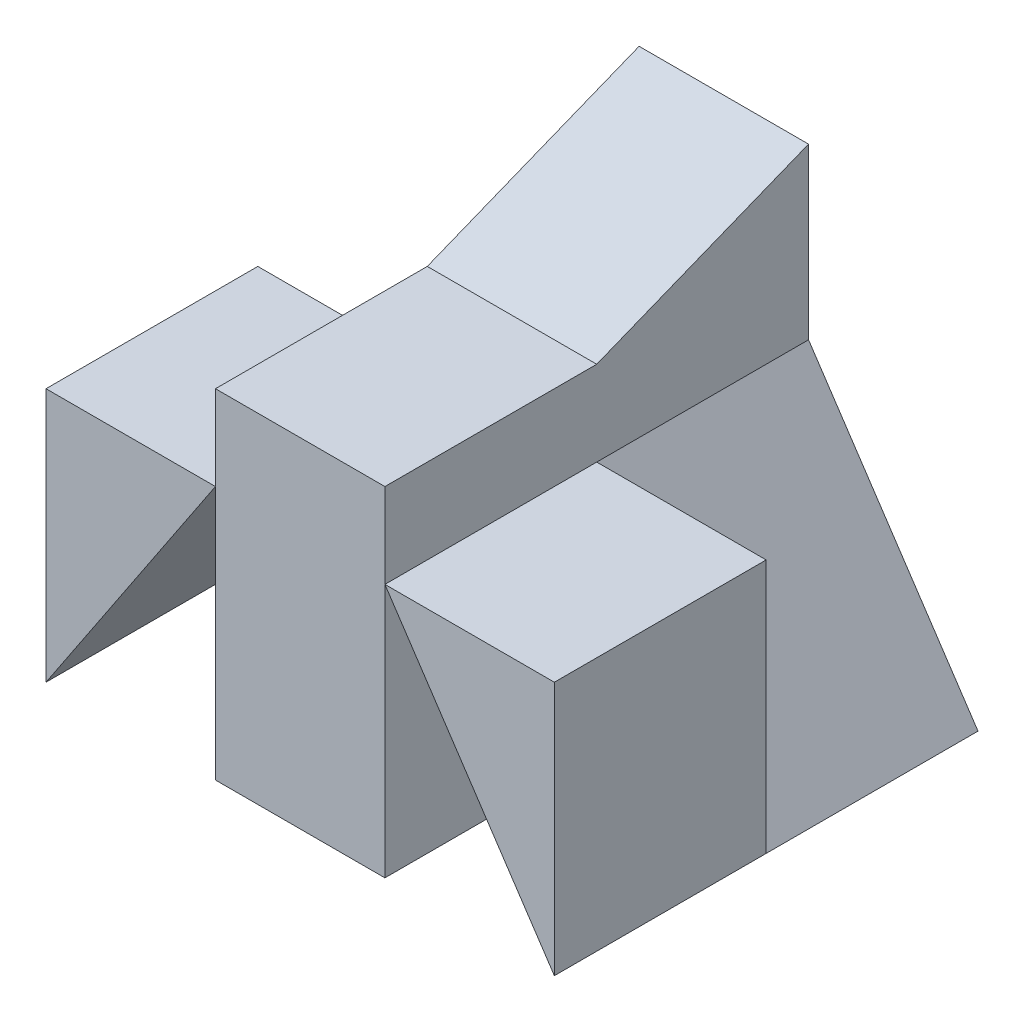
from build123d import *

# Parameters (mm, degrees)
SKETCH1_W           = 6
SKETCH1_H           = 3
SKETCH1_W_2         = 2
SKETCH1_H_2         = 2
BOSS_EXTRUDE1_DEPTH = 5
CUT_EXTRUDE2_DEPTH  = 5
CUT_EXTRUDE14_DEPTH = 2.5
CUT_EXTRUDE15_DEPTH = 2.5
CUT_EXTRUDE17_DEPTH = 2.5
CUT_EXTRUDE18_DEPTH = 2.5


with BuildPart() as part:
    # Sketch1 → Boss-Extrude1 (new body)
    with BuildSketch(Plane.XY):
        with Locations((3, 1.5)):
            Rectangle(SKETCH1_W, SKETCH1_H)
        with Locations((3, 4)):
            Rectangle(SKETCH1_W_2, SKETCH1_H_2)
    extrude(amount=BOSS_EXTRUDE1_DEPTH)

    # Sketch2 → Cut-Extrude2 (cut)
    with BuildSketch(Plane(origin=(4, 0, 0), x_dir=(0, 0, -1), z_dir=(1, 0, 0))):
        Polygon((0, 5), (-2.5, 4), (-5, 4), (-5, 5), align=None)
    extrude(amount=-CUT_EXTRUDE2_DEPTH, mode=Mode.SUBTRACT)

    # Sketch8 → Cut-Extrude14 (cut)
    with BuildSketch(Plane(origin=(0, 0, 0), x_dir=(-1, 0, 0), z_dir=(0, 0, -1))):
        Polygon((-4, 3), (-6, 0), (-6, 3), align=None)
    extrude(amount=-CUT_EXTRUDE14_DEPTH, mode=Mode.SUBTRACT)

    # Sketch9 → Cut-Extrude15 (cut)
    with BuildSketch(Plane.XY.offset(5)):
        Polygon((4, 3), (6, 0), (4, 0), align=None)
    extrude(amount=-CUT_EXTRUDE15_DEPTH, mode=Mode.SUBTRACT)

    # Sketch11 → Cut-Extrude17 (cut)
    with BuildSketch(Plane(origin=(0, 0, 0), x_dir=(-1, 0, 0), z_dir=(0, 0, -1))):
        Polygon((0, 3), (-2, 3), (0, 0), align=None)
    extrude(amount=-CUT_EXTRUDE17_DEPTH, mode=Mode.SUBTRACT)

    # Sketch10 → Cut-Extrude18 (cut)
    with BuildSketch(Plane.XY.offset(5)):
        Polygon((2, 3), (0, 0), (2, 0), align=None)
    extrude(amount=-CUT_EXTRUDE18_DEPTH, mode=Mode.SUBTRACT)


solid = part.part
